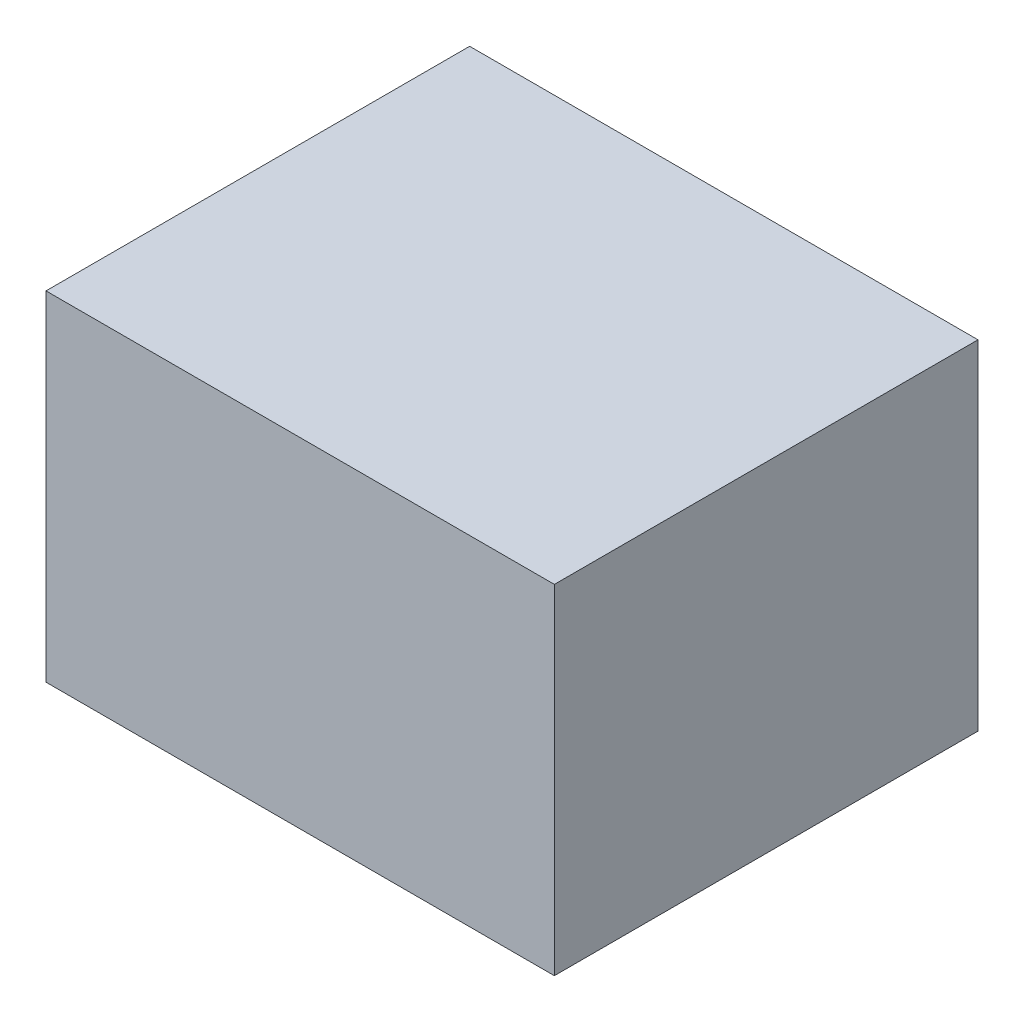
from build123d import *

# Parameters (mm, degrees)
SKETCH40_W          = 31.75
SKETCH40_H          = 25.4
BOSS_EXTRUDE8_DEPTH = 19.05


with BuildPart() as part:
    # Sketch40 → Boss-Extrude8 (new body, symmetric)
    with BuildSketch(Plane(origin=(0, 0, 0), x_dir=(0, 0, -1), z_dir=(1, 0, 0))):
        Rectangle(SKETCH40_W, SKETCH40_H)
    extrude(amount=BOSS_EXTRUDE8_DEPTH, both=True)


solid = part.part
